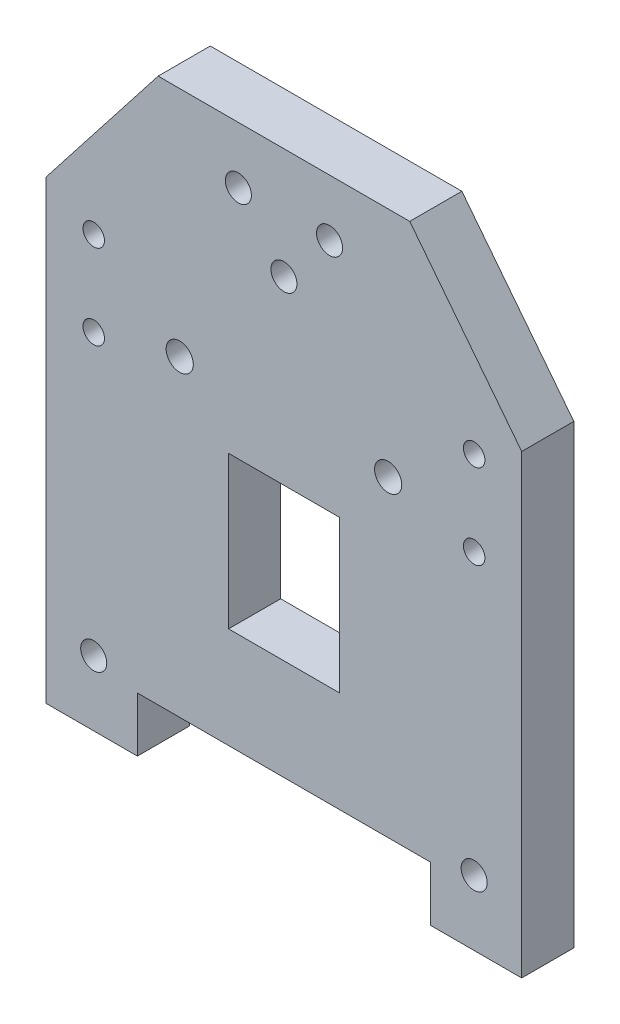
from build123d import *

# Parameters (mm, degrees)
ESBO_O1_R                = 2
ESBO_O1_R_2              = 2.086716092
ESBO_O1_R_3              = 2.086717953
RESSALTO_EXTRUS_O1_DEPTH = 8
ESBO_O4_R                = 1.65
CORTE_EXTRUS_O1_DEPTH    = 9


with BuildPart() as part:
    # Esboço1 → Ressalto-extrusão1 (new body)
    with BuildSketch(Plane.XY):
        Polygon((19.311716217, 92), (-19.311716217, 92), (-36.5, 70), (-36.5, 0), (-22.499999998, 0), (-22.499999998, 8.400000004), (22.499999998, 8.400000004), (22.499999998, 0), (36.5, 0), (36.5, 70), align=None)
        with Locations((0, 75)):
            Circle(ESBO_O1_R, mode=Mode.SUBTRACT)
        with Locations((-7, 83.3)):
            Circle(ESBO_O1_R, mode=Mode.SUBTRACT)
        with Locations((7, 83.3)):
            Circle(ESBO_O1_R, mode=Mode.SUBTRACT)
        with Locations((-29.2, 10)):
            Circle(ESBO_O1_R, mode=Mode.SUBTRACT)
        with Locations((29.2, 10)):
            Circle(ESBO_O1_R, mode=Mode.SUBTRACT)
        with Locations((-16, 56.354540575)):
            Circle(ESBO_O1_R_2, mode=Mode.SUBTRACT)
        with Locations((16, 56.354540575)):
            Circle(ESBO_O1_R_3, mode=Mode.SUBTRACT)
        Polygon((0, 47.257129716), (8.5, 47.257129716), (8.5, 23.917682695), (0, 23.917682695), (-8.5, 23.917682695), (-8.5, 47.257129716), align=None, mode=Mode.SUBTRACT)
    extrude(amount=RESSALTO_EXTRUS_O1_DEPTH)

    # Esboço4 → Corte-extrusão1 (cut, through all)
    with BuildSketch(Plane.XY.offset(8)):
        with Locations((-29.2, 66)):
            Circle(ESBO_O4_R)
        with Locations((-29.2, 53)):
            Circle(ESBO_O4_R)
        with Locations((29.2, 53)):
            Circle(ESBO_O4_R)
        with Locations((29.2, 66)):
            Circle(ESBO_O4_R)
    extrude(amount=-CORTE_EXTRUS_O1_DEPTH, mode=Mode.SUBTRACT)


solid = part.part
